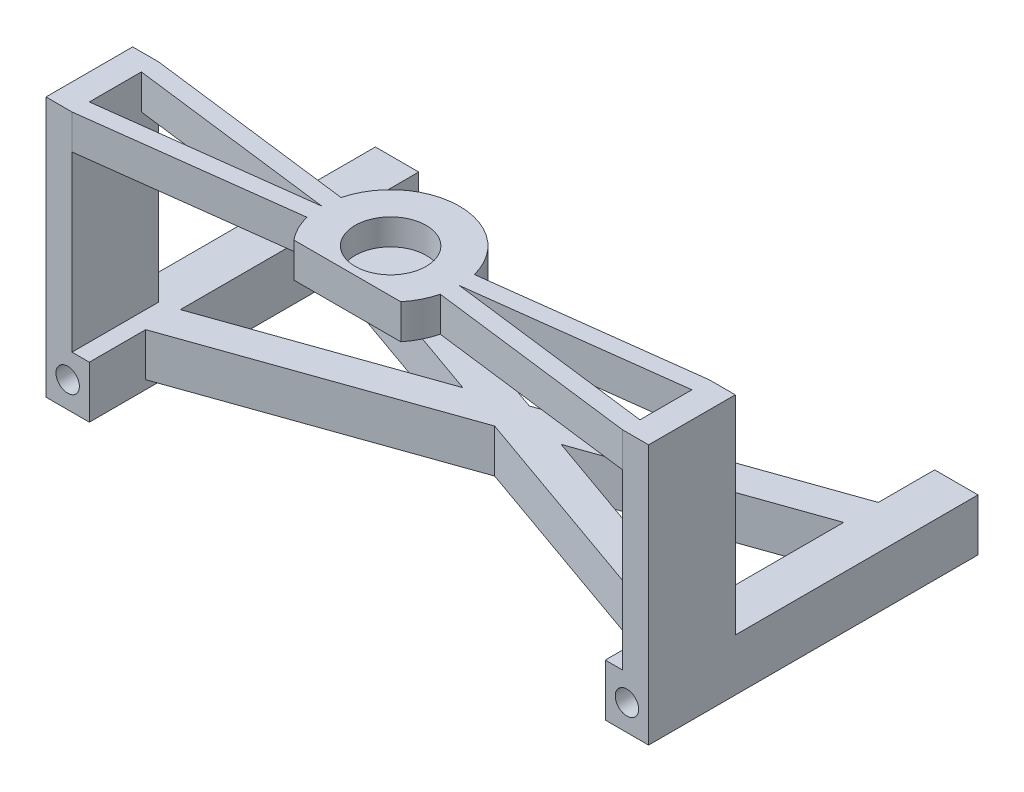
from build123d import *

# Parameters (mm, degrees)
BOSS_EXTRUDE1_DEPTH     = 5
BOSS_EXTRUDE2_DEPTH     = 1
SKETCH2_R               = 1.35
CUT_EXTRUDE1_DEPTH      = 39
BOSS_EXTRUDE3_START     = -6
SKETCH3_W               = 3
SKETCH3_H               = 10
BOSS_EXTRUDE3_DEPTH     = 20
BOSS_EXTRU_1_DEPTH      = 4
BOSS_EXTRU_2_DEPTH      = 4
ESQUISSE2_R             = 4.1
ENL_V_MAT_EXTRU_1_DEPTH = 3


with BuildPart() as part:
    # Sketch1 → Boss-Extrude1 (new body)
    with BuildSketch(Plane(origin=(0, 0, 0), x_dir=(1, 0, 0), z_dir=(0, 1, 0))):
        Polygon((2.5, 0), (0, 0), (0, 25), (2.5, 25), (2.5, 31.5), (-2.5, 31.5), (-2.5, -6.5), (2.5, -6.5), align=None)
        Polygon((0, 25), (0, 0), (2.5, 0), (2.5, 4), (2.5, 21), (2.5, 25), align=None)
        Polygon((32.26, 14.5), (2.5, 25), (2.5, 21), (26.591428571, 12.5), align=None)
        Polygon((26.591428571, 12.5), (32.26, 10.5), (37.928571429, 12.5), (32.26, 14.5), align=None)
        Polygon((32.26, 14.5), (37.928571429, 12.5), (62.02, 21), (62.02, 25), align=None)
        Polygon((2.5, 4), (2.5, 0), (32.26, 10.5), (26.591428571, 12.5), align=None)
        Polygon((32.26, 10.5), (62.02, 0), (62.02, 4), (37.928571429, 12.5), align=None)
        Polygon((64.52, 0), (62.02, 0), (62.02, -6.5), (67.02, -6.5), (67.02, 31.5), (62.02, 31.5), (62.02, 25), (64.52, 25), align=None)
        Polygon((62.02, 4), (62.02, 0), (64.52, 0), (64.52, 25), (62.02, 25), (62.02, 21), align=None)
    extrude(amount=BOSS_EXTRUDE1_DEPTH)

    # Sketch1_3 → Boss-Extrude2 (add)
    with BuildSketch(Plane(origin=(0, 0, 0), x_dir=(1, 0, 0), z_dir=(0, 1, 0))):
        Polygon((0, 25), (0, 0), (2.5, 0), (2.5, 4), (2.5, 21), (2.5, 25), align=None)
        Polygon((2.5, 0), (0, 0), (0, 25), (2.5, 25), (2.5, 31.5), (-2.5, 31.5), (-2.5, -6.5), (2.5, -6.5), align=None)
        Polygon((62.02, 4), (62.02, 0), (64.52, 0), (64.52, 25), (62.02, 25), (62.02, 21), align=None)
        Polygon((64.52, 0), (62.02, 0), (62.02, -6.5), (67.02, -6.5), (67.02, 31.5), (62.02, 31.5), (62.02, 25), (64.52, 25), align=None)
    extrude(amount=-BOSS_EXTRUDE2_DEPTH)

    # Sketch2 → Cut-Extrude1 (cut, through all)
    with BuildSketch(Plane(origin=(0, 0, -31.5), x_dir=(-1, 0, 0), z_dir=(0, 0, -1))):
        with Locations((0, 2)):
            Circle(SKETCH2_R)
        with Locations((-64.52, 2)):
            Circle(SKETCH2_R)
    extrude(amount=-CUT_EXTRUDE1_DEPTH, mode=Mode.SUBTRACT)

    # Sketch3 → Boss-Extrude3 (add)
    with BuildSketch(Plane(origin=(0, -1, 0), x_dir=(-1, 0, 0), z_dir=(0, -1, 0)).offset(BOSS_EXTRUDE3_START)):
        with Locations((1, -1.5)):
            Rectangle(SKETCH3_W, SKETCH3_H)
        with Locations((-65.52, -1.5)):
            Rectangle(SKETCH3_W, SKETCH3_H)
    extrude(amount=-BOSS_EXTRUDE3_DEPTH)

    # Sketch4 → Boss.-Extru.1 (add)
    with BuildSketch(Plane(origin=(0, 25, 0), x_dir=(-1, 0, 0), z_dir=(0, -1, 0))):
        Polygon((-0.5, -6.5), (-32.26, -2.5), (-64.02, -6.5), (-67.02, -6.5), (-67.02, 3.5), (-64.02, 3.5), (-32.26, -0.5), (-0.5, 3.5), (2.5, 3.5), (2.5, -6.5), align=None)
        Polygon((-0.5, 1.5), (-24.32, -1.5), (-0.5, -4.5), align=None, mode=Mode.SUBTRACT)
        Polygon((-40.2, -1.5), (-64.02, -4.5), (-64.02, 1.5), align=None, mode=Mode.SUBTRACT)
    extrude(amount=-BOSS_EXTRU_1_DEPTH)

    # Esquisse1 → Boss.-Extru.2 (add)
    with BuildSketch(Plane(origin=(0, 29, 0), x_dir=(1, 0, 0), z_dir=(0, 1, 0))):
        with BuildLine():
            Line((26.092050584, -6.5), (38.427949416, -6.5))
            ThreePointArc((38.427949416, -6.5), (32.26, 6.44), (26.092050584, -6.5))
        make_face()
    extrude(amount=-BOSS_EXTRU_2_DEPTH)

    # Esquisse2 → Enlèv. mat.-Extru.1 (cut)
    with BuildSketch(Plane(origin=(0, 29, 0), x_dir=(1, 0, 0), z_dir=(0, 1, 0))):
        with Locations((32.26, -1.5)):
            Circle(ESQUISSE2_R)
    extrude(amount=-ENL_V_MAT_EXTRU_1_DEPTH, mode=Mode.SUBTRACT)


solid = part.part
